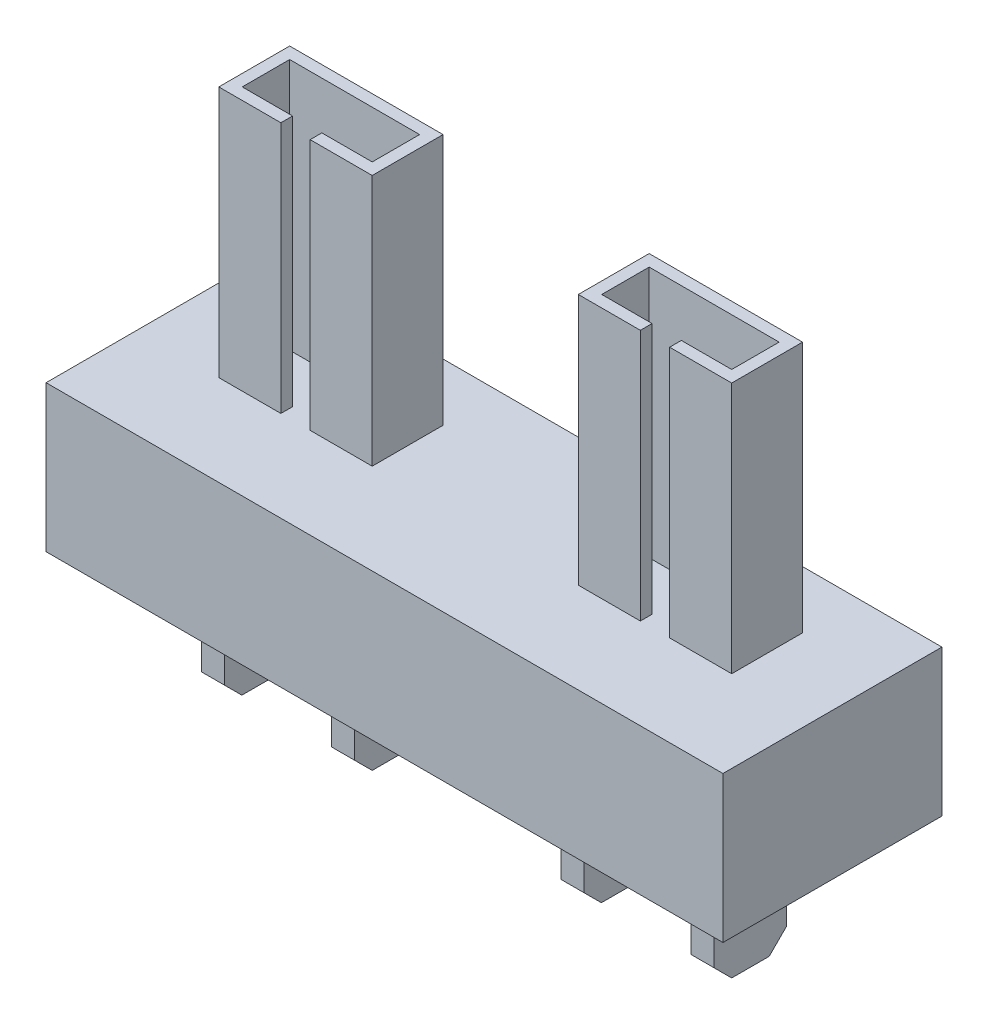
from build123d import *

# Parameters (mm, degrees)
SKETCH1_W           = 14.6812
SKETCH1_H           = 3.175
BOSS_EXTRUDE1_DEPTH = 2.3749
SKETCH2_W           = 0.5
SKETCH2_H           = 1.5748
BOSS_EXTRUDE2_DEPTH = 2.54
CHAMFER1_SIZE       = 0.381
BOSS_EXTRUDE3_DEPTH = 5.461


with BuildPart() as part:
    # Sketch1 → Boss-Extrude1 (new body, symmetric)
    with BuildSketch(Plane.XY):
        Rectangle(SKETCH1_W, SKETCH1_H)
    extrude(amount=BOSS_EXTRUDE1_DEPTH, both=True)

    # Sketch2 → Boss-Extrude2 (add)
    with BuildSketch(Plane.XZ.offset(1.5875)):
        with Locations((-5.3122, 0)):
            Rectangle(SKETCH2_W, SKETCH2_H)
        with Locations((-2.4852, 0)):
            Rectangle(SKETCH2_W, SKETCH2_H)
        with Locations((2.4852, 0)):
            Rectangle(SKETCH2_W, SKETCH2_H)
        with Locations((5.3122, 0)):
            Rectangle(SKETCH2_W, SKETCH2_H)
    extrude(amount=BOSS_EXTRUDE2_DEPTH)

    # Chamfer1
    chamfer1_edges = [part.edges().sort_by_distance(p)[0] for p in [
        (-5.3122, -4.1275, -0.7874),
        (-5.3122, -4.1275, 0.7874),
        (-2.4852, -4.1275, -0.7874),
        (-2.4852, -4.1275, 0.7874),
        (2.4852, -4.1275, 0.7874),
        (2.4852, -4.1275, -0.7874),
        (5.3122, -4.1275, 0.7874),
        (5.3122, -4.1275, -0.7874),
    ]]
    chamfer(chamfer1_edges, length=CHAMFER1_SIZE)

    # Sketch3 → Boss-Extrude3 (add)
    with BuildSketch(Plane(origin=(0, 1.5875, 0), x_dir=(1, 0, 0), z_dir=(0, 1, 0))):
        Polygon((-5.3082, 0.8763), (-2.4892, 0.8763), (-2.4892, -0.1524), (-3.5812, -0.1524), (-3.5812, -0.4064), (-2.2352, -0.4064), (-2.2352, 1.1303), (-5.5622, 1.1303), (-5.5622, -0.4064), (-4.2162, -0.4064), (-4.2162, -0.1524), (-5.3082, -0.1524), align=None)
        Polygon((5.5622, 1.1303), (5.5622, -0.4064), (4.2162, -0.4064), (4.2162, -0.1524), (5.3082, -0.1524), (5.3082, 0.8763), (2.4892, 0.8763), (2.4892, -0.1524), (3.5812, -0.1524), (3.5812, -0.4064), (2.2352, -0.4064), (2.2352, 1.1303), align=None)
    extrude(amount=BOSS_EXTRUDE3_DEPTH)


solid = part.part
